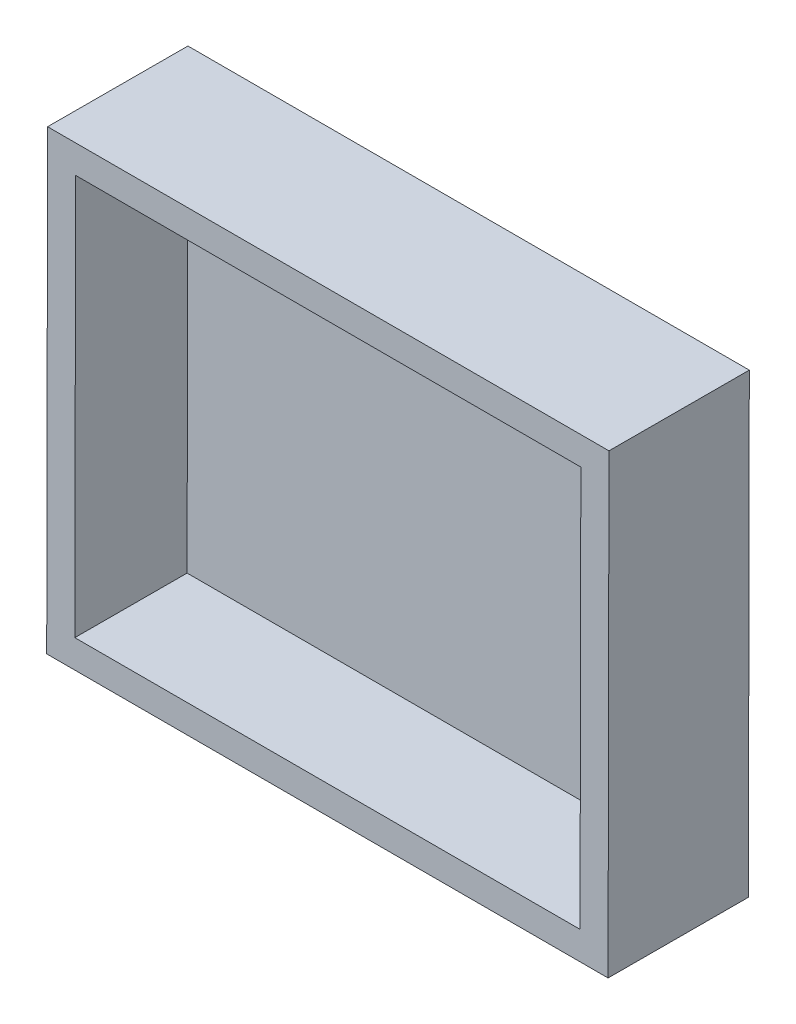
from build123d import *

# Parameters (mm, degrees)
BOSS_EXTRUDE1_DEPTH = 20
SHELL2_T            = -4


with BuildPart() as part:
    # Sketch2 → Boss-Extrude1 (new body)
    with BuildSketch(Plane(origin=(-1e-09, -0.00010259, -0.052603991), x_dir=(1, 0, -1.2e-08), z_dir=(1.2e-08, 0.001950226, 0.999998098))):
        Polygon((-75.063999083, -32.893592991), (-67.504997012, -32.893592991), (4.936001691, -32.893592991), (4.936001691, 32.106283405), (-2.495998153, 32.10628351), (-62.495998239, 32.106284359), (-75.063999083, 32.106284359), align=None)
    extrude(amount=BOSS_EXTRUDE1_DEPTH)

    # Shell2
    shell2_openings = [part.faces().sort_by_distance(p)[0] for p in [
        (-40.55039837, 6.145223556, 19.93544972),
    ]]
    offset(amount=SHELL2_T, openings=shell2_openings, kind=Kind.INTERSECTION)


solid = part.part
